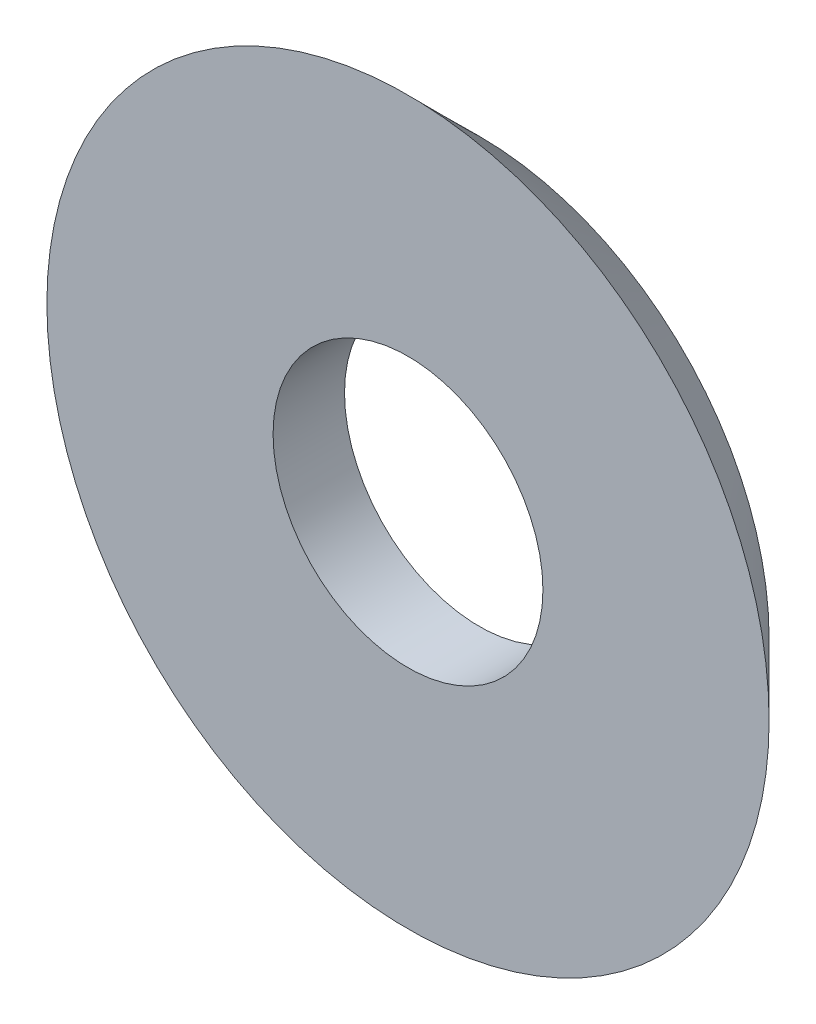
from build123d import *

# Parameters (mm, degrees)
SKETCH1_W = 3.9
SKETCH1_H = 1.8


with BuildPart() as part:
    # Sketch1 → Revolve1 (revolve)
    with BuildSketch(Plane(origin=(0, 0, 0), x_dir=(1, 0, 0), z_dir=(0, 1, 0))):
        with Locations((5.35, 0.9)):
            Rectangle(SKETCH1_W, SKETCH1_H)
        Polygon((7.3, 0), (9.1, 0), (7.3, 1.8), align=None)
    revolve(axis=Axis((0, 0, 0), (0, 0, -1)))


solid = part.part
